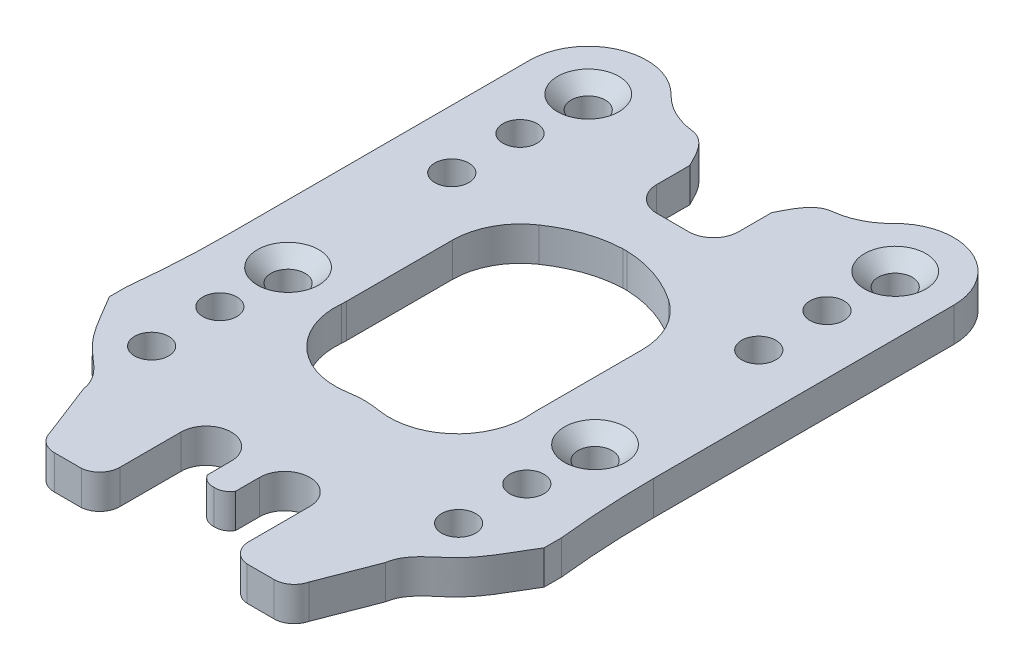
from build123d import *

# Parameters (mm, degrees)
BOSS_EXTRUDE1_DEPTH            = 5
M6_CLEARANCE_HOLE1_D           = 5
M6_CLEARANCE_HOLE1_CSINK_D     = 9
M6_CLEARANCE_HOLE1_CSINK_ANGLE = 90
M6X1_0_TAPPED_HOLE1_D          = 5


with BuildPart() as part:
    # Sketch1 → Boss-Extrude1 (new body)
    with BuildSketch(Plane(origin=(0, 0, 0), x_dir=(1, 0, 0), z_dir=(0, 1, 0))):
        with BuildLine():
            Line((69.154429566, 13.47085249), (69.154429566, 16.004009211))
            ThreePointArc((69.154429566, 16.004009211), (68.568623983, 23.140876552), (68.373161278, 30.2990773))
            Line((68.373161278, 30.2990773), (68.373161278, 48.133269951))
            Line((68.373161278, 48.133269951), (68.373161278, 53.582502285))
            Line((68.373161278, 53.582502285), (68.373161278, 74.2990773))
            ThreePointArc((68.373161278, 74.2990773), (63.00118115, 82.261470023), (53.60664117, 80.261348294))
            ThreePointArc((53.60664117, 80.261348294), (50.863204763, 78.250955414), (47.60463673, 77.276349225))
            add(Edge.make_bspline(
                [(43.284305461, 72.691623988), (43.987930263, 74.072264243), (45.137867804, 76.695348328), (47.258032118, 77.234650193), (47.60463673, 77.276349225)],
                knots=[0, 0, 0, 0, 0.393067042, 0.466810905, 0.466810905, 0.466810905, 0.466810905], degree=3))
            Line((43.284305461, 72.691623988), (43.284305461, 67.837570304))
            ThreePointArc((43.284305461, 67.837570304), (42.213675848, 65.252841772), (39.628947316, 64.182212159))
            Line((39.628947316, 64.182212159), (34.94347173, 64.182212159))
            ThreePointArc((34.94347173, 64.182212159), (32.358743198, 65.252841772), (31.288113585, 67.837570304))
            Line((31.288113585, 67.837570304), (31.288113585, 72.691623988))
            add(Edge.make_bspline(
                [(31.288113585, 72.691623988), (30.584488782, 74.072264242), (29.434551241, 76.695348328), (27.314386927, 77.234650193), (26.967782316, 77.276349225)],
                knots=[0, 0, 0, 0, 0.393067042, 0.466810905, 0.466810905, 0.466810905, 0.466810905], degree=3))
            ThreePointArc((26.967782316, 77.276349225), (23.709214283, 78.250955414), (20.965777876, 80.261348294))
            ThreePointArc((20.965777876, 80.261348294), (11.571237896, 82.261470023), (6.199257768, 74.2990773))
            Line((6.199257768, 74.2990773), (6.199257768, 53.582502285))
            Line((6.199257768, 53.582502285), (6.199257768, 48.133269951))
            Line((6.199257768, 48.133269951), (6.199257768, 30.2990773))
            ThreePointArc((6.199257768, 30.2990773), (6.003795063, 23.140876552), (5.41798948, 16.004009211))
            Line((5.41798948, 16.004009211), (5.41798948, 13.47085249))
            add(Edge.make_bspline(
                [(5.41798948, 13.47085249), (7.046412561, 10.903861817), (9.447890726, 5.623503132), (14.765538488, 2.695653096), (15.189698257, -0.049535855)],
                knots=[0, 0, 0, 0, 0.546916624, 1, 1, 1, 1], degree=3))
            Line((15.189698257, -0.049535855), (18.315949534, -8.138840351))
            ThreePointArc((18.315949534, -8.138840351), (19.364485683, -9.737903523), (21.173403671, -10.357779963))
            Line((21.173403671, -10.357779963), (25.170614374, -10.357779963))
            ThreePointArc((25.170614374, -10.357779963), (27.074415678, -9.397871639), (27.84130194, -7.408457441))
            Line((27.84130194, -7.408457441), (27.84130194, 1.545841867))
            ThreePointArc((27.84130194, 1.545841867), (31.527431336, 5.231971263), (35.213560733, 1.545841867))
            Line((35.213560733, 1.545841867), (35.213560733, -1.95624117))
            ThreePointArc((35.213560733, -1.95624117), (36.093993872, -2.799009437), (37.286209528, -3.05207602))
            ThreePointArc((37.286209528, -3.05207602), (38.478425184, -2.799009437), (39.358858323, -1.95624117))
            Line((39.358858323, -1.95624117), (39.358858323, 1.545841867))
            ThreePointArc((39.358858323, 1.545841867), (43.044987714, 5.231971258), (46.731117106, 1.545841867))
            Line((46.731117106, 1.545841867), (46.731117106, -7.408457441))
            ThreePointArc((46.731117106, -7.408457441), (47.498003369, -9.39787164), (49.401804673, -10.357779963))
            Line((49.401804673, -10.357779963), (53.399015375, -10.357779963))
            ThreePointArc((53.399015375, -10.357779963), (55.207933362, -9.737903523), (56.256469511, -8.138840351))
            Line((56.256469511, -8.138840351), (59.382720789, -0.049535855))
            add(Edge.make_bspline(
                [(69.154429566, 13.47085249), (67.526006485, 10.903861817), (65.12452832, 5.623503132), (59.806880557, 2.695653096), (59.382720789, -0.049535855)],
                knots=[0, 0, 0, 0, 0.546916624, 1, 1, 1, 1], degree=3))
        make_face()
        with BuildLine():
            Line((37.590365628, 57.198418754), (36.982053418, 57.198418754))
            add(Edge.make_bspline(
                [(27.789822398, 54.075777582), (30.499523282, 55.89941311), (33.552733603, 57.080263172), (36.982053418, 57.198418754)],
                knots=[0.681705089, 0.681705089, 0.681705089, 0.681705089, 1, 1, 1, 1], degree=3))
            ThreePointArc((27.789822398, 54.075777582), (24.546117922, 50.47890197), (23.373161278, 45.779614194))
            Line((23.373161278, 45.779614194), (23.373161278, 30.2990773))
            ThreePointArc((23.373161278, 30.2990773), (23.364804799, 29.920337919), (23.339751629, 29.542335687))
            ThreePointArc((23.339751629, 29.542335687), (26.460419501, 21.366644617), (34.819518268, 18.777057732))
            add(Edge.make_bspline(
                [(34.819518268, 18.777057732), (35.231027882, 18.840286024), (36.0539589, 18.949507928), (36.875794913, 19.003560622), (37.286209523, 19.011619704)],
                knots=[0.850973756, 0.850973756, 0.850973756, 0.850973756, 0.895462137, 0.939950518, 0.939950518, 0.939950518, 0.939950518], degree=3))
            add(Edge.make_bspline(
                [(39.752900778, 18.777057732), (39.341391163, 18.840286024), (38.518460146, 18.949507928), (37.696624133, 19.003560622), (37.286209523, 19.011619704)],
                knots=[0.850973756, 0.850973756, 0.850973756, 0.850973756, 0.895462137, 0.939950518, 0.939950518, 0.939950518, 0.939950518], degree=3))
            ThreePointArc((39.752900778, 18.777057732), (48.111999545, 21.366644617), (51.232667416, 29.542335687))
            ThreePointArc((51.232667416, 29.542335687), (51.207614246, 29.920337919), (51.199257768, 30.2990773))
            Line((51.199257768, 30.2990773), (51.199257768, 45.779614194))
            ThreePointArc((51.199257768, 45.779614194), (50.026301124, 50.47890197), (46.782596648, 54.075777582))
            add(Edge.make_bspline(
                [(46.782596648, 54.075777582), (44.072895763, 55.89941311), (41.019685443, 57.080263172), (37.590365628, 57.198418754)],
                knots=[0.681705089, 0.681705089, 0.681705089, 0.681705089, 1, 1, 1, 1], degree=3))
        make_face(mode=Mode.SUBTRACT)
    extrude(amount=BOSS_EXTRUDE1_DEPTH)

    # M6 Clearance Hole1 (through all)
    with Locations(Plane(origin=(0, 5, 0), x_dir=(1, 0, 0), z_dir=(0, 1, 0))):
        with Locations((14.786209523, 74.2990773), (59.786209523, 74.2990773), (14.786209523, 30.2990773), (59.786209523, 30.2990773)):
            CounterSinkHole(M6_CLEARANCE_HOLE1_D / 2, M6_CLEARANCE_HOLE1_CSINK_D / 2, counter_sink_angle=M6_CLEARANCE_HOLE1_CSINK_ANGLE)

    # M6x1.0 Tapped Hole1 (through all)
    with Locations(Plane(origin=(0, 5, 0), x_dir=(1, 0, 0), z_dir=(0, 1, 0))):
        with Locations((14.786209523, 54.2990773), (59.786209523, 54.2990773), (14.786209523, 10.2990773), (59.786209523, 10.2990773), (14.786209523, 64.2990773), (59.786209523, 64.2990773), (59.786209523, 20.2990773), (14.786209523, 20.2990773)):
            Hole(M6X1_0_TAPPED_HOLE1_D / 2)


solid = part.part
